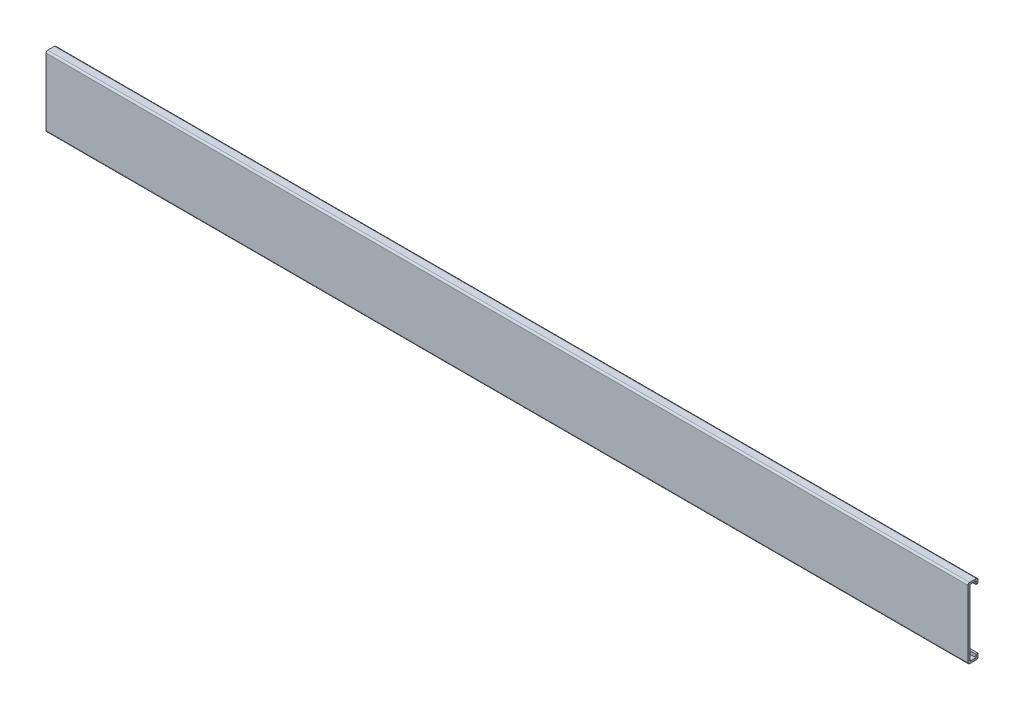
from build123d import *

# Parameters (mm, degrees)
EXTRUDE_3_DEPTH = 550


with BuildPart() as part:
    # Эскиз1 → Вытянуть-Тонкостенный3 (new body)
    with BuildSketch(Plane(origin=(0, 0, 0), x_dir=(0, 0, -1), z_dir=(1, 0, 0))):
        with BuildLine():
            Line((6, -18), (6, -20))
            ThreePointArc((6, -20), (5.707106781, -20.707106781), (5, -21))
            Line((5, -21), (1, -21))
            ThreePointArc((1, -21), (0.292893219, -20.707106781), (0, -20))
            Line((0, -20), (0, 20))
            ThreePointArc((0, 20), (0.292893219, 20.707106781), (1, 21))
            Line((1, 21), (5, 21))
            ThreePointArc((5, 21), (5.707106781, 20.707106781), (6, 20))
            Line((6, 20), (6, 18))
            Line((6, 18), (4.8, 18))
            Line((4.8, 18), (4.8, 19.8))
            Line((4.8, 19.8), (1.2, 19.8))
            Line((1.2, 19.8), (1.2, -19.8))
            Line((1.2, -19.8), (4.8, -19.8))
            Line((4.8, -19.8), (4.8, -18))
            Line((4.8, -18), (6, -18))
        make_face()
    extrude(amount=EXTRUDE_3_DEPTH)


solid = part.part
